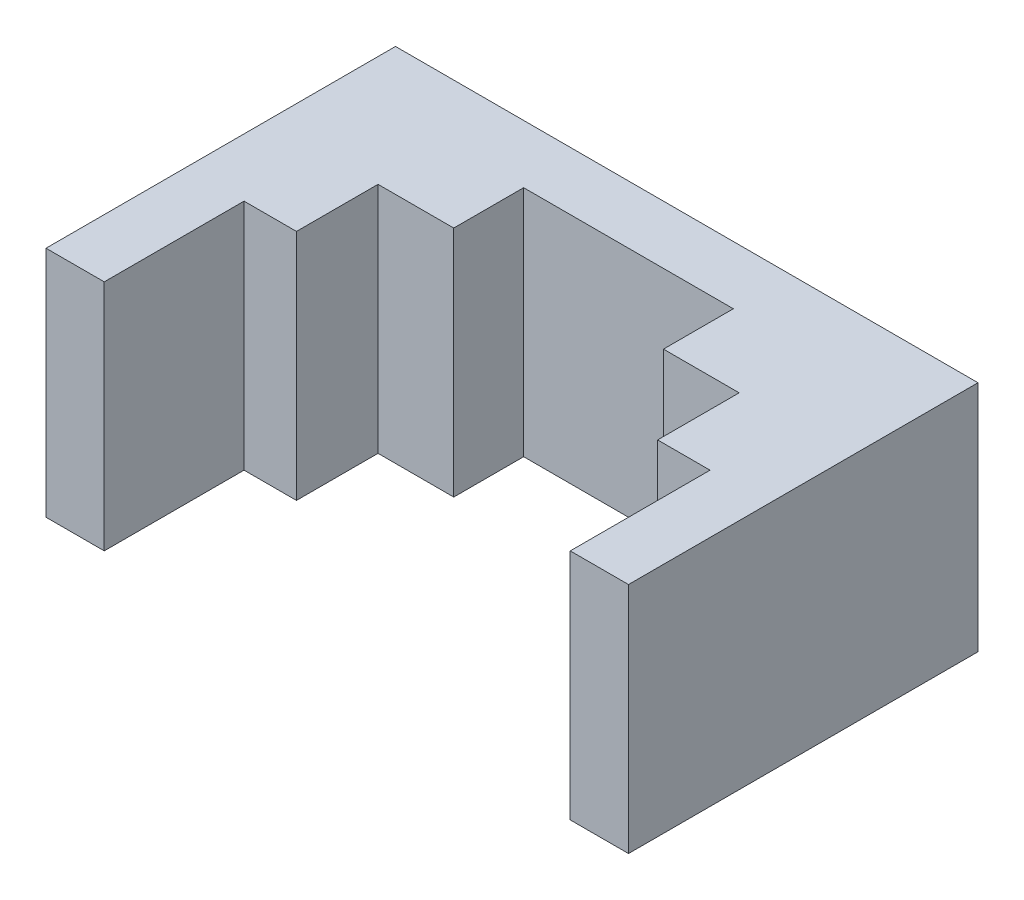
from build123d import *

# Parameters (mm, degrees)
SKETCH1_W           = 25
SKETCH1_H           = 10
BOSS_EXTRUDE1_DEPTH = 15
SKETCH2_W           = 20
SKETCH2_H           = 10
CUT_EXTRUDE1_DEPTH  = 6
SKETCH3_W           = 9
SKETCH3_H           = 10
CUT_EXTRUDE2_DEPTH  = 6.5
SKETCH4_W           = 15.5
SKETCH4_H           = 10
CUT_EXTRUDE3_DEPTH  = 3.5


with BuildPart() as part:
    # Sketch1 → Boss-Extrude1 (new body)
    with BuildSketch(Plane.XY):
        Rectangle(SKETCH1_W, SKETCH1_H)
    extrude(amount=BOSS_EXTRUDE1_DEPTH)

    # Sketch2 → Cut-Extrude1 (cut)
    with BuildSketch(Plane.XY.offset(15)):
        Rectangle(SKETCH2_W, SKETCH2_H)
    extrude(amount=-CUT_EXTRUDE1_DEPTH, mode=Mode.SUBTRACT)

    # Sketch3 → Cut-Extrude2 (cut)
    with BuildSketch(Plane.XY.offset(9)):
        Rectangle(SKETCH3_W, SKETCH3_H)
    extrude(amount=-CUT_EXTRUDE2_DEPTH, mode=Mode.SUBTRACT)

    # Sketch4 → Cut-Extrude3 (cut)
    with BuildSketch(Plane.XY.offset(9)):
        Rectangle(SKETCH4_W, SKETCH4_H)
    extrude(amount=-CUT_EXTRUDE3_DEPTH, mode=Mode.SUBTRACT)


solid = part.part
